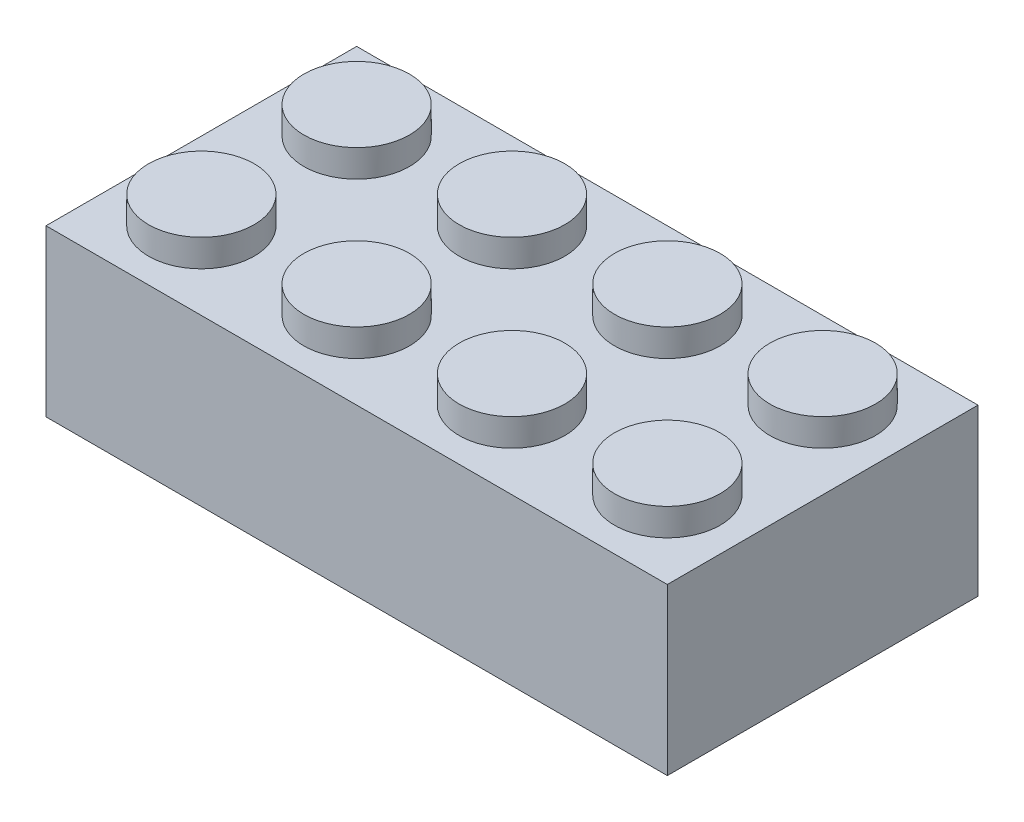
from build123d import *

# Parameters (mm, degrees)
SKETCH1_W            = 31.75
SKETCH1_H            = 15.875
BOSS_EXTRUDE1_DEPTH  = 4.2291
SKETCH2_W            = 29.21
SKETCH2_H            = 13.335
SKETCH2_R            = 3.175
SKETCH2_R_2          = 2.413
CUT_EXTRUDE1_DEPTH   = 7.1882
SKETCH3_R            = 2.69875
BOSS_EXTRUDE2_DEPTH  = 1.397
LPATTERN1_COUNT      = 4
LPATTERN1_PITCH      = 7.9375
LPATTERN1_COUNT_DIR2 = 2
LPATTERN1_PITCH_DIR2 = 7.9375
SKETCH2_3_R          = 3.175
SKETCH2_3_R_2        = 2.413
BOSS_EXTRUDE3_DEPTH  = 7.1882
LPATTERN2_COUNT      = 2
LPATTERN2_PITCH      = 7.9375
LPATTERN2_COL_COUNT  = 2
LPATTERN2_COL_PITCH  = 7.9375


with BuildPart() as part:
    # Sketch1 → Boss-Extrude1 (new, symmetric)
    with BuildSketch(Plane(origin=(0, 0, 0), x_dir=(1, 0, 0), z_dir=(0, 1, 0))):
        Rectangle(SKETCH1_W, SKETCH1_H)
    extrude(amount=BOSS_EXTRUDE1_DEPTH, both=True)

    # Sketch2 → Cut-Extrude1 (cut)
    with BuildSketch(Plane.XZ.offset(4.2291)):
        Rectangle(SKETCH2_W, SKETCH2_H)
        Circle(SKETCH2_R, mode=Mode.SUBTRACT)
        Circle(SKETCH2_R)
        Circle(SKETCH2_R_2, mode=Mode.SUBTRACT)
        Circle(SKETCH2_R_2)
    extrude(amount=-CUT_EXTRUDE1_DEPTH, mode=Mode.SUBTRACT)

    # Sketch3 → Boss-Extrude2 (add)
    with BuildSketch(Plane(origin=(0, 4.2291, 0), x_dir=(1, 0, 0), z_dir=(0, 1, 0))):
        with Locations(Location((11.90625, -3.96875, 0), (0, 0, 90))):
            Circle(SKETCH3_R)
    boss_extrude2 = extrude(amount=BOSS_EXTRUDE2_DEPTH)

    # LPattern1: Boss-Extrude2 4 × 2
    with Locations(*[(-i * LPATTERN1_PITCH, 0, -j * LPATTERN1_PITCH_DIR2) for i in range(LPATTERN1_COUNT) for j in range(LPATTERN1_COUNT_DIR2) if (i, j) != (0, 0)]):
        add(boss_extrude2)

    # Sketch2_3 → Boss-Extrude3 (add)
    with BuildSketch(Plane.XZ.offset(4.2291)):
        with Locations(Location((0, 0, 0), (0, 0, 270))):
            Circle(SKETCH2_3_R)
        with Locations(Location((0, 0, 0), (0, 0, 270))):
            Circle(SKETCH2_3_R_2, mode=Mode.SUBTRACT)
    boss_extrude3 = extrude(amount=-BOSS_EXTRUDE3_DEPTH)

    # LPattern2: Boss-Extrude3 ×2
    with Locations(*[(i * LPATTERN2_PITCH, 0, 0) for i in range(1, LPATTERN2_COUNT)]):
        add(boss_extrude3)

    # LPattern2 col: Boss-Extrude3 ×2
    with Locations(*[(-i * LPATTERN2_COL_PITCH, 0, 0) for i in range(1, LPATTERN2_COL_COUNT)]):
        add(boss_extrude3)


solid = part.part
